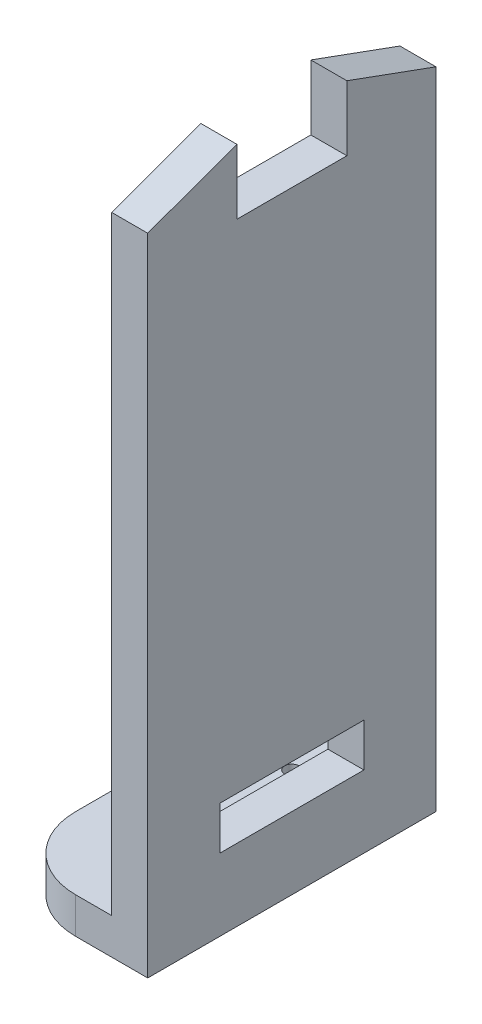
from build123d import *

# Parameters (mm, degrees)
SKETCH1_R           = 1
BOSS_EXTRUDE1_DEPTH = 5
BOSS_EXTRUDE2_DEPTH = 5
SKETCH6_W           = 20
SKETCH6_H           = 6
CUT_EXTRUDE1_DEPTH  = 5


with BuildPart() as part:
    # Sketch1 → Boss-Extrude1 (new body)
    with BuildSketch(Plane(origin=(0, 0, 0), x_dir=(1, 0, 0), z_dir=(0, 1, 0))):
        with BuildLine():
            Line((-6.063583, -8.020726268), (3.936417, -8.020726268))
            Line((3.936417, -8.020726268), (3.936417, 31.979273732))
            Line((3.936417, 31.979273732), (-6.063583, 31.979273732))
            ThreePointArc((-6.063583, 31.979273732), (-13.134650812, 29.050341544), (-16.063583, 21.979273732))
            Line((-16.063583, 21.979273732), (-16.063583, 1.979273732))
            ThreePointArc((-16.063583, 1.979273732), (-13.134650812, -5.09179408), (-6.063583, -8.020726268))
        make_face()
        with Locations((-6.063583, 21.979273732)):
            Circle(SKETCH1_R, mode=Mode.SUBTRACT)
        with Locations((-6.063583, 1.979273732)):
            Circle(SKETCH1_R, mode=Mode.SUBTRACT)
    extrude(amount=BOSS_EXTRUDE1_DEPTH)

    # Sketch5 → Boss-Extrude2 (add)
    with BuildSketch(Plane(origin=(3.936417, 0, 0), x_dir=(0, 0, -1), z_dir=(1, 0, 0))):
        Polygon((-8.020726268, 5), (31.979273732, 5), (31.979273732, 89.50779106), (19.612713583, 94.015582119), (19.612713583, 85), (4.345833881, 85), (4.345833881, 94.015582119), (-8.020726268, 89.50779106), align=None)
    extrude(amount=-BOSS_EXTRUDE2_DEPTH)

    # Sketch6 → Cut-Extrude1 (cut)
    with BuildSketch(Plane.ZY.offset(1.063583)):
        with Locations((-11.979273732, 13)):
            Rectangle(SKETCH6_W, SKETCH6_H)
    extrude(amount=-CUT_EXTRUDE1_DEPTH, mode=Mode.SUBTRACT)


solid = part.part
